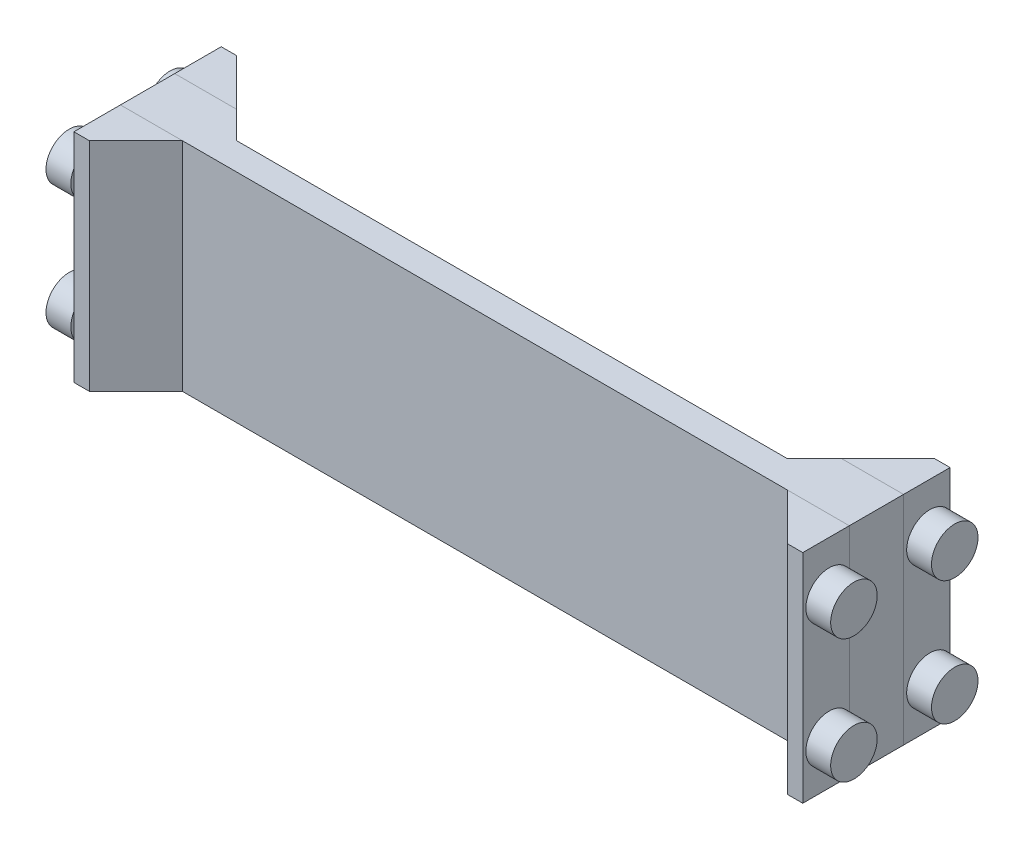
from build123d import *

# Parameters (mm, degrees)
SKETCH1_W             = 596.9
SKETCH1_H             = 177.8
BOSS_EXTRUDE1_DEPTH   = 44.45
BOSS_EXTRUDE2_DEPTH   = 177.8
BOSS_EXTRUDE2_2_DEPTH = 177.8
BOSS_EXTRUDE2_3_DEPTH = 177.8
BOSS_EXTRUDE2_4_DEPTH = 177.8
SKETCH3_R             = 12.7
BOSS_EXTRUDE3_DEPTH   = 2.54
SKETCH4_R             = 19.05
BOSS_EXTRUDE4_DEPTH   = 20.32
SKETCH5_R             = 19.05
BOSS_EXTRUDE5_DEPTH   = 20.32
SKETCH6_R             = 19.05
BOSS_EXTRUDE6_DEPTH   = 20.32
SKETCH7_R             = 19.05
BOSS_EXTRUDE7_DEPTH   = 20.32
SKETCH8_R             = 12.7
BOSS_EXTRUDE8_DEPTH   = 2.54
SKETCH9_R             = 19.05
BOSS_EXTRUDE9_DEPTH   = 20.32
SKETCH10_R            = 19.05
BOSS_EXTRUDE10_DEPTH  = 20.32
SKETCH11_R            = 19.05
BOSS_EXTRUDE11_DEPTH  = 20.32
SKETCH12_R            = 19.05
BOSS_EXTRUDE12_DEPTH  = 20.32
CUT_EXTRUDE1_DEPTH    = 304.8


with BuildPart() as part:
    # Sketch1 → Boss-Extrude1 (new body)
    with BuildSketch(Plane.XY):
        with Locations((211.765296898, -50.324573746)):
            Rectangle(SKETCH1_W, SKETCH1_H)
    extrude(amount=BOSS_EXTRUDE1_DEPTH)

    # Sketch13 → Cut-Extrude1 (cut)
    with BuildSketch(Plane.XZ.offset(139.224573746)):
        Polygon((459.415296898, 0), (-35.884703102, 0), (-13.659703102, 22.225), (437.190296898, 22.225), align=None)
    extrude(amount=-CUT_EXTRUDE1_DEPTH, mode=Mode.SUBTRACT)


with BuildPart() as body_2:
    # Sketch2 → Boss-Extrude2 (new body)
    with BuildSketch(Plane(origin=(0, 38.575426254, 0), x_dir=(1, 0, 0), z_dir=(0, 1, 0))):
        Polygon((497.515296898, -82.55), (510.215296898, -82.55), (510.215296898, -44.45), (459.415296898, -44.45), align=None)
    extrude(amount=-BOSS_EXTRUDE2_DEPTH)



with BuildPart() as body_3:
    # Sketch2 → Boss-Extrude2 2 (new body)
    with BuildSketch(Plane(origin=(0, 38.575426254, 0), x_dir=(1, 0, 0), z_dir=(0, 1, 0))):
        Polygon((459.415296898, 0), (510.215296898, 0), (510.215296898, 38.1), (497.515296898, 38.1), align=None)
    extrude(amount=-BOSS_EXTRUDE2_2_DEPTH)


with BuildPart() as body_4:
    # Sketch2 → Boss-Extrude2 3 (new body)
    with BuildSketch(Plane(origin=(0, 38.575426254, 0), x_dir=(1, 0, 0), z_dir=(0, 1, 0))):
        Polygon((-86.684703102, 38.1), (-86.684703102, 0), (-35.884703102, 0), (-73.984703102, 38.1), align=None)
    extrude(amount=-BOSS_EXTRUDE2_3_DEPTH)



with BuildPart() as body_5:
    # Sketch2 → Boss-Extrude2 4 (new body)
    with BuildSketch(Plane(origin=(0, 38.575426254, 0), x_dir=(1, 0, 0), z_dir=(0, 1, 0))):
        Polygon((-35.884703102, -44.45), (-86.684703102, -44.45), (-86.684703102, -82.55), (-73.984703102, -82.55), align=None)
    extrude(amount=-BOSS_EXTRUDE2_4_DEPTH)


with BuildPart() as body_2_1:
    add(body_2.part)

    add(body_3.part)  # Boss-Extrude3 merges body 3
    # Sketch3 → Boss-Extrude3 (add)
    with BuildSketch(Plane(origin=(510.215296898, 0, 0), x_dir=(0, 0, -1), z_dir=(1, 0, 0))):
        with Locations((-63.5, 0.475426254)):
            Circle(SKETCH3_R)
        with Locations((19.05, 0.475426254)):
            Circle(SKETCH3_R)
        with Locations((-63.5, -101.124573746)):
            Circle(SKETCH3_R)
        with Locations((19.05, -101.124573746)):
            Circle(SKETCH3_R)
    extrude(amount=BOSS_EXTRUDE3_DEPTH)

    # Sketch4 → Boss-Extrude4 (add)
    with BuildSketch(Plane(origin=(512.755296898, 0, 0), x_dir=(0, 0, -1), z_dir=(1, 0, 0))):
        with Locations((-63.5, 0.475426254)):
            Circle(SKETCH4_R)
    extrude(amount=BOSS_EXTRUDE4_DEPTH)

    # Sketch5 → Boss-Extrude5 (add)
    with BuildSketch(Plane(origin=(512.755296898, 0, 0), x_dir=(0, 0, -1), z_dir=(1, 0, 0))):
        with Locations((19.05, 0.475426254)):
            Circle(SKETCH5_R)
    extrude(amount=BOSS_EXTRUDE5_DEPTH)

    # Sketch6 → Boss-Extrude6 (add)
    with BuildSketch(Plane(origin=(512.755296898, 0, 0), x_dir=(0, 0, -1), z_dir=(1, 0, 0))):
        with Locations((19.05, -101.124573746)):
            Circle(SKETCH6_R)
    extrude(amount=BOSS_EXTRUDE6_DEPTH)

    # Sketch7 → Boss-Extrude7 (add)
    with BuildSketch(Plane(origin=(512.755296898, 0, 0), x_dir=(0, 0, -1), z_dir=(1, 0, 0))):
        with Locations((-63.5, -101.124573746)):
            Circle(SKETCH7_R)
    extrude(amount=BOSS_EXTRUDE7_DEPTH)


with BuildPart() as body_4_1:
    add(body_4.part)

    add(body_5.part)  # Boss-Extrude8 merges body 5
    # Sketch8 → Boss-Extrude8 (add)
    with BuildSketch(Plane.ZY.offset(86.684703102)):
        with Locations((-19.05, -101.124573746)):
            Circle(SKETCH8_R)
        with Locations((-19.05, 0.475426254)):
            Circle(SKETCH8_R)
        with Locations((63.5, 0.475426254)):
            Circle(SKETCH8_R)
        with Locations((63.5, -101.124573746)):
            Circle(SKETCH8_R)
    extrude(amount=BOSS_EXTRUDE8_DEPTH)

    # Sketch9 → Boss-Extrude9 (add)
    with BuildSketch(Plane.ZY.offset(89.224703102)):
        with Locations((63.5, -101.124573746)):
            Circle(SKETCH9_R)
    extrude(amount=BOSS_EXTRUDE9_DEPTH)

    # Sketch10 → Boss-Extrude10 (add)
    with BuildSketch(Plane.ZY.offset(89.224703102)):
        with Locations((63.5, 0.475426254)):
            Circle(SKETCH10_R)
    extrude(amount=BOSS_EXTRUDE10_DEPTH)

    # Sketch11 → Boss-Extrude11 (add)
    with BuildSketch(Plane.ZY.offset(89.224703102)):
        with Locations((-19.05, -101.124573746)):
            Circle(SKETCH11_R)
    extrude(amount=BOSS_EXTRUDE11_DEPTH)

    # Sketch12 → Boss-Extrude12 (add)
    with BuildSketch(Plane.ZY.offset(89.224703102)):
        with Locations((-19.05, 0.475426254)):
            Circle(SKETCH12_R)
    extrude(amount=BOSS_EXTRUDE12_DEPTH)


solid = Compound([part.part, body_2_1.part, body_4_1.part])
